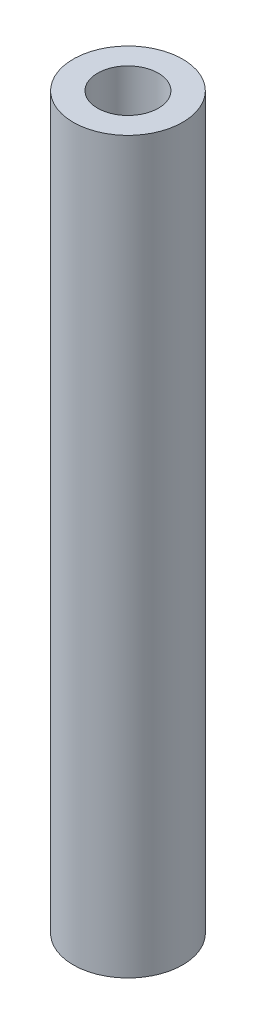
from build123d import *

# Parameters (mm, degrees)
SKETCH1_R           = 2.8575
SKETCH1_R_2         = 1.5875
BOSS_EXTRUDE1_DEPTH = 38.1


with BuildPart() as part:
    # Sketch1 → Boss-Extrude1 (new body)
    with BuildSketch(Plane(origin=(0, 0, 0), x_dir=(1, 0, 0), z_dir=(0, 1, 0))):
        with Locations((1.407896852, 0)):
            Circle(SKETCH1_R)
        with Locations((1.407896852, 0)):
            Circle(SKETCH1_R_2, mode=Mode.SUBTRACT)
    extrude(amount=BOSS_EXTRUDE1_DEPTH)


solid = part.part
